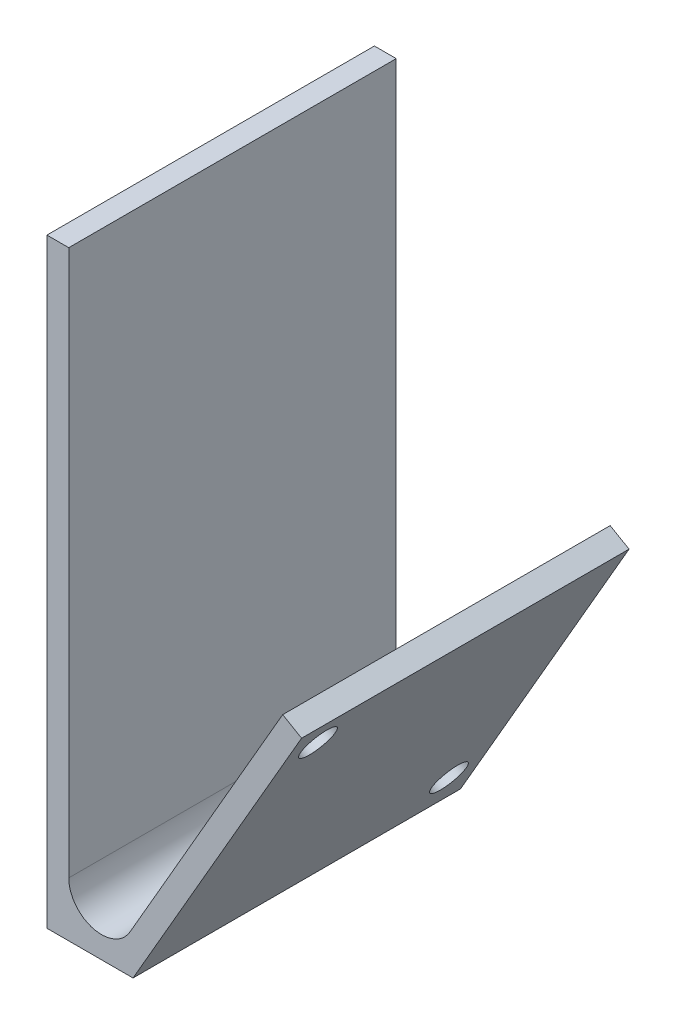
from build123d import *

# Parameters (mm, degrees)
RESSALTO_EXTRUS_O1_DEPTH = 30
ESBO_O2_R                = 1.6
CORTE_EXTRUS_O1_DEPTH    = 30


with BuildPart() as part:
    # Esboço1 → Ressalto-extrusão1 (new body)
    with BuildSketch(Plane.XY):
        with BuildLine():
            Line((0, 55), (0, 0))
            Line((0, 0), (7.886751346, 0))
            Line((7.886751346, 0), (23.330127019, 26.748711306))
            Line((23.330127019, 26.748711306), (21.598076211, 27.748711306))
            Line((21.598076211, 27.748711306), (7.598076211, 3.5))
            ThreePointArc((7.598076211, 3.5), (4.223542865, 2.102222521), (2, 5))
            Line((2, 5), (2, 55))
            Line((2, 55), (0, 55))
        make_face()
    extrude(amount=RESSALTO_EXTRUS_O1_DEPTH)

    # Esboço2 → Corte-extrusão1 (cut)
    with BuildSketch(Plane(origin=(4.183012702, -2.415063509, 0), x_dir=(0.5, 0.866025404, 0), z_dir=(-0.866025404, 0.5, 0))):
        with Locations((31.830127019, -27)):
            Circle(ESBO_O2_R)
        with Locations((7.830127019, -3)):
            Circle(ESBO_O2_R)
    extrude(amount=-CORTE_EXTRUS_O1_DEPTH, mode=Mode.SUBTRACT)


solid = part.part
